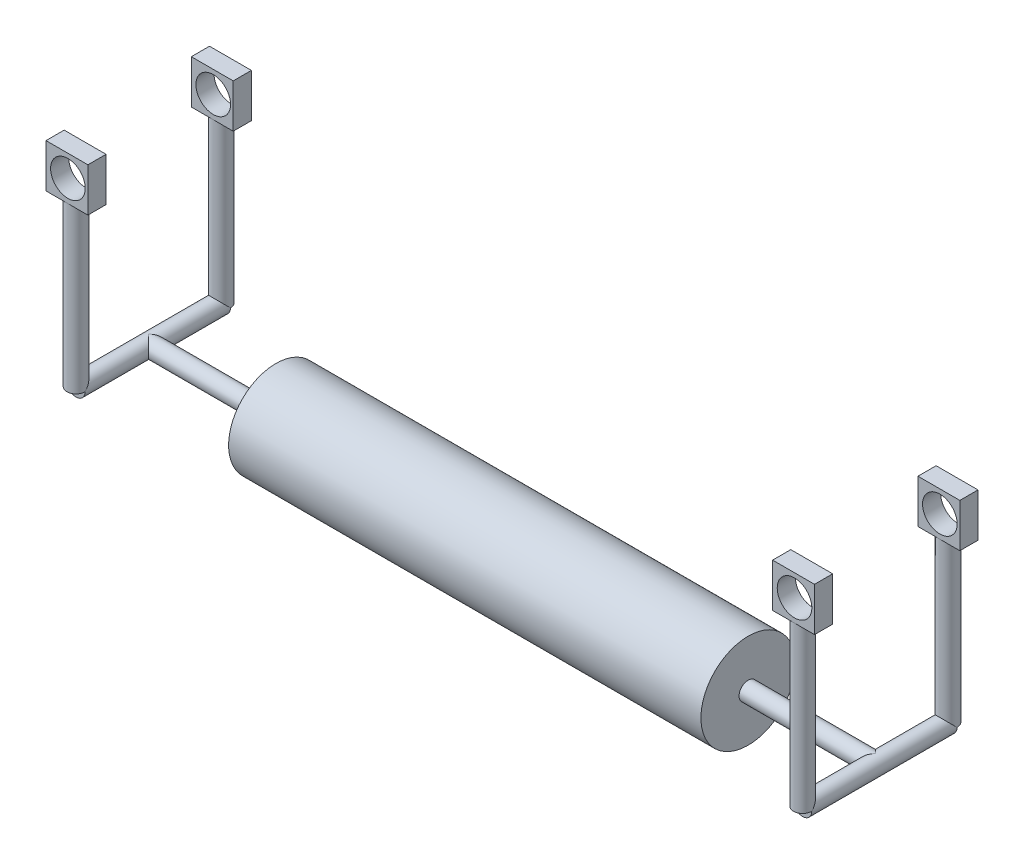
from build123d import *

# Parameters (mm, degrees)
BOSS_EXTRUDE1_DEPTH       = 65
BOSS_EXTRUDE1_DEPTH_BACK  = 65
SKETCH1_R                 = 13
SKETCH6_R                 = 2.5
BOSS_EXTRUDE5_DEPTH       = 35
BOSS_EXTRUDE6_START       = 35
SKETCH7_R                 = 2.5
BOSS_EXTRUDE6_DEPTH       = 35
BOSS_EXTRUDE7_DEPTH       = 20
BOSS_EXTRUDE7_DEPTH_BACK  = 20
SKETCH10_R                = 2.5
SKETCH11_R                = 2.5
BOSS_EXTRUDE8_DEPTH       = 45
SKETCH12_W                = 11.53
SKETCH12_H                = 5
BOSS_EXTRUDE9_DEPTH       = 12
CUT_EXTRUDE2_DEPTH        = 66
CUT_EXTRUDE2_DEPTH_BACK   = 12
SKETCH13_R                = 4.765
BOSS_EXTRUDE10_DEPTH      = 20
BOSS_EXTRUDE10_DEPTH_BACK = 20
SKETCH14_R                = 2.5
SKETCH15_R                = 2.5
BOSS_EXTRUDE11_DEPTH      = 45
SKETCH16_W                = 11.53
SKETCH16_H                = 5
BOSS_EXTRUDE12_DEPTH      = 12
CUT_EXTRUDE3_DEPTH        = 12
CUT_EXTRUDE3_DEPTH_BACK   = 51
SKETCH17_R                = 4.765


with BuildPart() as part:
    # Sketch1 → Boss-Extrude1 (new, two sides: drawn at the far end of the back side and taken through both)
    with BuildSketch(Plane(origin=(0, 0, 0), x_dir=(0, 0, -1), z_dir=(1, 0, 0)).offset(-BOSS_EXTRUDE1_DEPTH_BACK)):
        Circle(SKETCH1_R)
    extrude(amount=BOSS_EXTRUDE1_DEPTH + BOSS_EXTRUDE1_DEPTH_BACK)

    # Sketch6 → Boss-Extrude5 (add)
    with BuildSketch(Plane(origin=(65, 0, 0), x_dir=(0, 0, -1), z_dir=(1, 0, 0))):
        Circle(SKETCH6_R)
    extrude(amount=BOSS_EXTRUDE5_DEPTH)

    # Sketch7 → Boss-Extrude6 (add)
    with BuildSketch(Plane.ZY.offset(65).offset(BOSS_EXTRUDE6_START)):
        Circle(SKETCH7_R)
    extrude(amount=-BOSS_EXTRUDE6_DEPTH)

    # Sketch10 → Boss-Extrude7 (add, two sides: drawn at the far end of the back side and taken through both)
    with BuildSketch(Plane.YX.offset(-BOSS_EXTRUDE7_DEPTH_BACK)):
        with Locations((0, 100)):
            Circle(SKETCH10_R)
    extrude(amount=BOSS_EXTRUDE7_DEPTH + BOSS_EXTRUDE7_DEPTH_BACK)

    # Sketch11 → Boss-Extrude8 (add)
    with BuildSketch(Plane(origin=(0, 0, 0), x_dir=(1, 0, 0), z_dir=(0, 1, 0))):
        with Locations((100, -20)):
            Circle(SKETCH11_R)
        with Locations((100, 20)):
            Circle(SKETCH11_R)
    extrude(amount=BOSS_EXTRUDE8_DEPTH)

    # Sketch12 → Boss-Extrude9 (add)
    with BuildSketch(Plane(origin=(0, 45, 0), x_dir=(1, 0, 0), z_dir=(0, 1, 0))):
        with Locations((100, -20)):
            Rectangle(SKETCH12_W, SKETCH12_H)
        with Locations((100, 20)):
            Rectangle(SKETCH12_W, SKETCH12_H)
    extrude(amount=BOSS_EXTRUDE9_DEPTH)

    # Sketch13 → Cut-Extrude2 (cut, two sides: drawn at the far end of the back side and taken through both)
    with BuildSketch(Plane.XY.offset(-17.5).offset(-CUT_EXTRUDE2_DEPTH_BACK)):
        with Locations((100.265, 51)):
            Circle(SKETCH13_R)
    extrude(amount=CUT_EXTRUDE2_DEPTH + CUT_EXTRUDE2_DEPTH_BACK, mode=Mode.SUBTRACT)

    # Sketch14 → Boss-Extrude10 (add, two sides: drawn at the far end of the back side and taken through both)
    with BuildSketch(Plane.XY.offset(-BOSS_EXTRUDE10_DEPTH_BACK)):
        with Locations((-100, 0)):
            Circle(SKETCH14_R)
    extrude(amount=BOSS_EXTRUDE10_DEPTH + BOSS_EXTRUDE10_DEPTH_BACK)

    # Sketch15 → Boss-Extrude11 (add)
    with BuildSketch(Plane(origin=(0, 0, 0), x_dir=(1, 0, 0), z_dir=(0, 1, 0))):
        with Locations((-100, 20)):
            Circle(SKETCH15_R)
        with Locations((-100, -20)):
            Circle(SKETCH15_R)
    extrude(amount=BOSS_EXTRUDE11_DEPTH)

    # Sketch16 → Boss-Extrude12 (add)
    with BuildSketch(Plane(origin=(0, 45, 0), x_dir=(1, 0, 0), z_dir=(0, 1, 0))):
        with Locations((-100, -20)):
            Rectangle(SKETCH16_W, SKETCH16_H)
        with Locations((-100, 20)):
            Rectangle(SKETCH16_W, SKETCH16_H)
    extrude(amount=BOSS_EXTRUDE12_DEPTH)

    # Sketch17 → Cut-Extrude3 (cut, two sides: drawn at the far end of the back side and taken through both)
    with BuildSketch(Plane.XY.offset(22.5).offset(-CUT_EXTRUDE3_DEPTH_BACK)):
        with Locations((-99.735, 51)):
            Circle(SKETCH17_R)
    extrude(amount=CUT_EXTRUDE3_DEPTH + CUT_EXTRUDE3_DEPTH_BACK, mode=Mode.SUBTRACT)


solid = part.part
